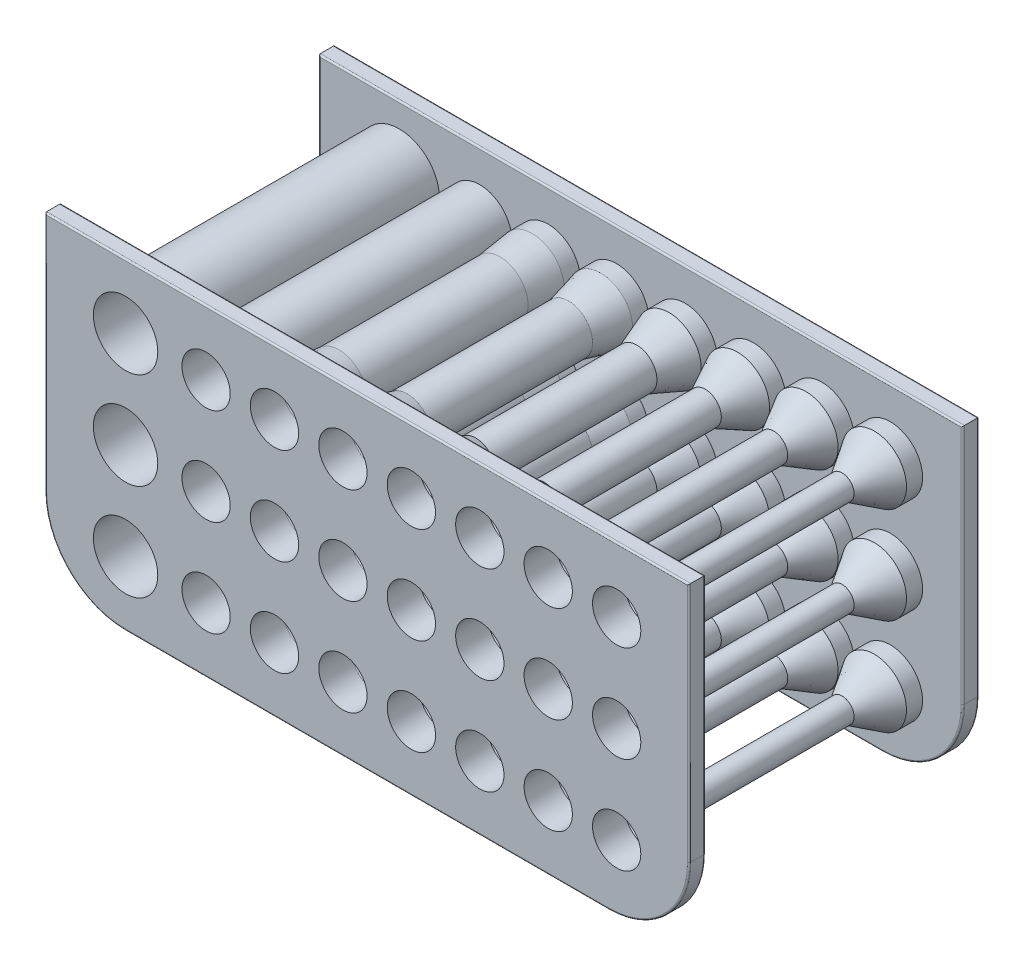
from build123d import *

# Parameters (mm, degrees)
SKIZZE1_R                          = 5
SKIZZE1_R_2                        = 4
EXTRUDE_THIN2_DEPTH                = 18
SKIZZE1_R_3                        = 3
EXTRUDE_THIN2_2_DEPTH              = 18
SKIZZE1_R_4                        = 3.5
SKIZZE1_R_5                        = 2.5
EXTRUDE_THIN2_3_DEPTH              = 18
SKIZZE1_R_6                        = 2
EXTRUDE_THIN2_4_DEPTH              = 18
SKIZZE1_R_7                        = 1.5
EXTRUDE_THIN2_5_DEPTH              = 18
SKIZZE1_R_8                        = 1
EXTRUDE_THIN2_6_DEPTH              = 18
SKIZZE1_R_9                        = 1.75
SKIZZE1_R_10                       = 0.75
EXTRUDE_THIN2_7_DEPTH              = 18
SKIZZE1_R_11                       = 0.5
EXTRUDE_THIN2_8_DEPTH              = 18
SKETCH1_W                          = 80
SKETCH1_H                          = 40
BOSS_EXTRUDE1_DEPTH                = 2
FILLET1_R                          = 10
LPATTERN2_COUNT                    = 2
LPATTERN2_PITCH                    = 34
FILLET1_OF_LPATTERN2_R             = 10
SKIZZE1_3_R                        = 4
SKIZZE1_3_R_2                      = 3
SKIZZE1_3_R_3                      = 2.5
SKIZZE1_3_R_4                      = 2
SKIZZE1_3_R_5                      = 1.5
SKIZZE1_3_R_6                      = 1
SKIZZE1_3_R_7                      = 0.75
SKIZZE1_3_R_8                      = 0.5
CUT_EXTRUDE1_DEPTH                 = 18
SKETCH7_R                          = 4
CUT_EXTRUDE2_DEPTH                 = 8
SKETCH7_3_R                        = 4
SKETCH7_3_R_2                      = 3
EXTRUDE_THIN3_DEPTH                = 4
FILLET3_R                          = 0.2
LINEARES_MUSTER1_COUNT             = 2
LINEARES_MUSTER1_PITCH             = 12
LINEARES_MUSTER1_COUNT_DIR2        = 2
LINEARES_MUSTER1_PITCH_DIR2        = 12
LINEARES_MUSTER1_COPY_1_SKETCH_R   = 4
LINEARES_MUSTER1_COPY_1_DEPTH      = 8
LINEARES_MUSTER1_COPY_2_SKETCH_R   = 4
LINEARES_MUSTER1_COPY_2_DEPTH      = 8
LINEARES_MUSTER1_COPY_3_SKETCH_R   = 4
LINEARES_MUSTER1_COPY_3_DEPTH      = 8
LINEARES_MUSTER1_COPY_4_SKETCH_R   = 4
LINEARES_MUSTER1_COPY_4_SKETCH_R_2 = 3
LINEARES_MUSTER1_COPY_4_DEPTH      = 4
LINEARES_MUSTER1_COPY_5_SKETCH_R   = 4
LINEARES_MUSTER1_COPY_5_SKETCH_R_2 = 3
LINEARES_MUSTER1_COPY_5_DEPTH      = 4
LINEARES_MUSTER1_COPY_6_SKETCH_R   = 4
LINEARES_MUSTER1_COPY_6_SKETCH_R_2 = 3
LINEARES_MUSTER1_COPY_6_DEPTH      = 4


with BuildPart() as part:
    # Skizze1 → Extrude-Thin2 (new, symmetric)
    with BuildSketch(Plane.XY):
        with Locations((-30, 0)):
            Circle(SKIZZE1_R)
        with Locations((-30, 0)):
            Circle(SKIZZE1_R_2, mode=Mode.SUBTRACT)
    extrude_thin2 = extrude(amount=EXTRUDE_THIN2_DEPTH, both=True)



with BuildPart() as body_2:
    # Skizze1 → Extrude-Thin2 2 (new, symmetric)
    with BuildSketch(Plane.XY):
        with Locations((-20, 0)):
            Circle(SKIZZE1_R_2)
        with Locations((-20, 0)):
            Circle(SKIZZE1_R_3, mode=Mode.SUBTRACT)
    extrude_thin2_2 = extrude(amount=EXTRUDE_THIN2_2_DEPTH, both=True)


with BuildPart() as body_3:
    # Skizze1 → Extrude-Thin2 3 (new, symmetric)
    with BuildSketch(Plane.XY):
        with Locations((-11.5, 0)):
            Circle(SKIZZE1_R_4)
        with Locations((-11.5, 0)):
            Circle(SKIZZE1_R_5, mode=Mode.SUBTRACT)
    extrude_thin2_3 = extrude(amount=EXTRUDE_THIN2_3_DEPTH, both=True)


with BuildPart() as body_4:
    # Skizze1 → Extrude-Thin2 4 (new, symmetric)
    with BuildSketch(Plane.XY):
        with Locations((-3, 0)):
            Circle(SKIZZE1_R_3)
        with Locations((-3, 0)):
            Circle(SKIZZE1_R_6, mode=Mode.SUBTRACT)
    extrude_thin2_4 = extrude(amount=EXTRUDE_THIN2_4_DEPTH, both=True)


with BuildPart() as body_5:
    # Skizze1 → Extrude-Thin2 5 (new, symmetric)
    with BuildSketch(Plane.XY):
        with Locations((5.5, 0)):
            Circle(SKIZZE1_R_5)
        with Locations((5.5, 0)):
            Circle(SKIZZE1_R_7, mode=Mode.SUBTRACT)
    extrude_thin2_5 = extrude(amount=EXTRUDE_THIN2_5_DEPTH, both=True)


with BuildPart() as body_6:
    # Skizze1 → Extrude-Thin2 6 (new, symmetric)
    with BuildSketch(Plane.XY):
        with Locations((14, 0)):
            Circle(SKIZZE1_R_6)
        with Locations((14, 0)):
            Circle(SKIZZE1_R_8, mode=Mode.SUBTRACT)
    extrude_thin2_6 = extrude(amount=EXTRUDE_THIN2_6_DEPTH, both=True)


with BuildPart() as body_7:
    # Skizze1 → Extrude-Thin2 7 (new, symmetric)
    with BuildSketch(Plane.XY):
        with Locations((22.5, 0)):
            Circle(SKIZZE1_R_9)
        with Locations((22.5, 0)):
            Circle(SKIZZE1_R_10, mode=Mode.SUBTRACT)
    extrude_thin2_7 = extrude(amount=EXTRUDE_THIN2_7_DEPTH, both=True)


with BuildPart() as body_8:
    # Skizze1 → Extrude-Thin2 8 (new, symmetric)
    with BuildSketch(Plane.XY):
        with Locations((31, 0)):
            Circle(SKIZZE1_R_7)
        with Locations((31, 0)):
            Circle(SKIZZE1_R_11, mode=Mode.SUBTRACT)
    extrude_thin2_8 = extrude(amount=EXTRUDE_THIN2_8_DEPTH, both=True)


with BuildPart() as part_1:
    add(part.part)

    add(body_2.part)  # Boss-Extrude1 merges body 2

    add(body_3.part)  # Boss-Extrude1 merges body 3

    add(body_4.part)  # Boss-Extrude1 merges body 4

    add(body_5.part)  # Boss-Extrude1 merges body 5

    add(body_6.part)  # Boss-Extrude1 merges body 6

    add(body_7.part)  # Boss-Extrude1 merges body 7

    add(body_8.part)  # Boss-Extrude1 merges body 8
    # Sketch1 → Boss-Extrude1 (add)
    with BuildSketch(Plane.XY.offset(18)):
        Rectangle(SKETCH1_W, SKETCH1_H)
    boss_extrude1 = extrude(amount=-BOSS_EXTRUDE1_DEPTH)

    # Fillet1
    fillet1_edges = [part_1.edges().sort_by_distance(p)[0] for p in [
        (40, -20, 17),
        (-40, -20, 17),
    ]]
    fillet(fillet1_edges, radius=FILLET1_R)

    # LPattern2: Boss-Extrude1 ×2
    with Locations(*[(0, 0, -i * LPATTERN2_PITCH) for i in range(1, LPATTERN2_COUNT)]):
        add(boss_extrude1)

    # Fillet1 of LPattern2
    fillet1_of_lpattern2_edges = [part_1.edges().sort_by_distance(p)[0] for p in [
        (40, -20, -17),
        (-40, -20, -17),
    ]]
    fillet(fillet1_of_lpattern2_edges, radius=FILLET1_OF_LPATTERN2_R)

    # Skizze1_3 → Cut-Extrude1 (cut, symmetric)
    with BuildSketch(Plane.XY):
        with Locations((-30, 0)):
            Circle(SKIZZE1_3_R)
        with Locations((-20, 0)):
            Circle(SKIZZE1_3_R_2)
        with Locations((-11.5, 0)):
            Circle(SKIZZE1_3_R_3)
        with Locations((-3, 0)):
            Circle(SKIZZE1_3_R_4)
        with Locations((5.5, 0)):
            Circle(SKIZZE1_3_R_5)
        with Locations((14, 0)):
            Circle(SKIZZE1_3_R_6)
        with Locations((22.5, 0)):
            Circle(SKIZZE1_3_R_7)
        with Locations((31, 0)):
            Circle(SKIZZE1_3_R_8)
    cut_extrude1 = extrude(amount=CUT_EXTRUDE1_DEPTH, both=True, mode=Mode.SUBTRACT)

    # Sketch7 → Cut-Extrude2 (cut)
    with BuildSketch(Plane.XY.offset(18)):
        with Locations((31, 0)):
            Circle(SKETCH7_R)
        with Locations((22.5, 0)):
            Circle(SKETCH7_R)
        with Locations((14, 0)):
            Circle(SKETCH7_R)
        with Locations((5.5, 0)):
            Circle(SKETCH7_R)
        with Locations((-3, 0)):
            Circle(SKETCH7_R)
        with Locations((-11.5, 0)):
            Circle(SKETCH7_R)
    cut_extrude2 = extrude(amount=-CUT_EXTRUDE2_DEPTH, mode=Mode.SUBTRACT)

    # Sketch7_3 → Extrude-Thin3 (add)
    with BuildSketch(Plane.XY.offset(18)):
        with Locations((31, 0)):
            Circle(SKETCH7_3_R)
        with Locations((31, 0)):
            Circle(SKETCH7_3_R_2, mode=Mode.SUBTRACT)
        with Locations((22.5, 0)):
            Circle(SKETCH7_3_R)
        with Locations((22.5, 0)):
            Circle(SKETCH7_3_R_2, mode=Mode.SUBTRACT)
        with Locations((14, 0)):
            Circle(SKETCH7_3_R)
        with Locations((14, 0)):
            Circle(SKETCH7_3_R_2, mode=Mode.SUBTRACT)
        with Locations((5.5, 0)):
            Circle(SKETCH7_3_R)
        with Locations((5.5, 0)):
            Circle(SKETCH7_3_R_2, mode=Mode.SUBTRACT)
        with Locations((-3, 0)):
            Circle(SKETCH7_3_R)
        with Locations((-3, 0)):
            Circle(SKETCH7_3_R_2, mode=Mode.SUBTRACT)
        with Locations((-11.5, 0)):
            Circle(SKETCH7_3_R)
        with Locations((-11.5, 0)):
            Circle(SKETCH7_3_R_2, mode=Mode.SUBTRACT)
    extrude_thin3 = extrude(amount=-EXTRUDE_THIN3_DEPTH)

    # Sketch8 → Revolve2 (revolve)
    with BuildSketch(Plane(origin=(0, 0, 0), x_dir=(1, 0, 0), z_dir=(0, 1, 0))):
        Polygon((8.5, -14), (9.5, -14), (8, -10), (7, -10), align=None)
    revolve2 = revolve(axis=Axis((5.5, 0, 14), (0, 0, 1)))

    # Sketch22 → Revolve3 (revolve)
    with BuildSketch(Plane(origin=(0, 0, 0), x_dir=(1, 0, 0), z_dir=(0, 1, 0))):
        Polygon((16, -10), (18, -14), (17, -14), (15, -10), align=None)
    revolve3 = revolve(axis=Axis((14, 0, 14), (0, 0, 1)))

    # Sketch23 → Revolve4 (revolve)
    with BuildSketch(Plane(origin=(0, 0, 0), x_dir=(1, 0, 0), z_dir=(0, 1, 0))):
        Polygon((24.25, -10), (26.5, -14), (25.5, -14), (23.25, -10), align=None)
    revolve4 = revolve(axis=Axis((22.5, 0, 14), (0, 0, 1)))

    # Sketch24 → Revolve5 (revolve)
    with BuildSketch(Plane(origin=(0, 0, 0), x_dir=(1, 0, 0), z_dir=(0, 1, 0))):
        Polygon((35, -14), (34, -14), (31.5, -10), (32.5, -10), align=None)
    revolve5 = revolve(axis=Axis((31, 0, 14), (0, 0, 1)))

    # Skizze2 → Rotation1 (revolve)
    with BuildSketch(Plane(origin=(0, 0, 0), x_dir=(1, 0, 0), z_dir=(0, 1, 0))):
        Polygon((0, -10), (1, -14), (0, -14), (-1, -10), align=None)
    rotation1 = revolve(axis=Axis((-3, 0, 14), (0, 0, 1)))

    # Skizze3 → Rotation2 (revolve)
    with BuildSketch(Plane(origin=(0, 0, 0), x_dir=(1, 0, 0), z_dir=(0, 1, 0))):
        Polygon((-8, -10), (-7.5, -14), (-8.5, -14), (-9, -10), align=None)
    rotation2 = revolve(axis=Axis((-11.5, 0, 14), (0, 0, 1)))

    # Fillet3
    fillet3_edges = [part_1.edges().sort_by_distance(p)[0] for p in [
        (-35, 0, -16),
        (-24, 0, -16),
        (-15, 0, -16),
        (-6, 0, -16),
        (3, 0, -16),
        (12, 0, -16),
        (20.75, 0, -16),
        (29.5, 0, -16),
        (-40, 5, -18),
        (0, 20, -18),
        (0, 20, -16),
        (-40, 5, -16),
        (-40, 5, 16),
        (0, 20, 16),
        (0, 20, 18),
        (-40, 5, 18),
        (0, -20, -16),
        (0, -20, -18),
        (40, 5, -16),
        (-37.071067812, -17.071067812, -16),
        (37.071067812, -17.071067812, -16),
        (40, 5, -18),
        (-37.071067812, -17.071067812, -18),
        (37.071067812, -17.071067812, -18),
        (-34, 0, -18),
        (-34, 0, 18),
        (-23, 0, -18),
        (-23, 0, 18),
        (-14, 0, -18),
        (-5, 0, -18),
        (4, 0, -18),
        (13, 0, -18),
        (21.75, 0, -18),
        (30.5, 0, -18),
        (-24, 0, 16),
        (27, 0, 16),
        (28, 0, 18),
        (18.5, 0, 16),
        (19.5, 0, 18),
        (10, 0, 16),
        (11, 0, 18),
        (1.5, 0, 16),
        (2.5, 0, 18),
        (-7, 0, 16),
        (-6, 0, 18),
        (-15.5, 0, 16),
        (-14.5, 0, 18),
        (0, -20, 18),
        (0, -20, 16),
        (40, 5, 18),
        (-37.071067812, -17.071067812, 18),
        (37.071067812, -17.071067812, 18),
        (40, 5, 16),
        (-37.071067812, -17.071067812, 16),
        (37.071067812, -17.071067812, 16),
        (-35, 0, 16),
    ]]
    fillet(fillet3_edges, radius=FILLET3_R)

    # Spiegeln1: Cut-Extrude2, Extrude-Thin3, Revolve2, Revolve3, Revolve4, Revolve5, Rotation1, Rotation2 across plane
    add(cut_extrude2.mirror(Plane.XY), mode=Mode.SUBTRACT)
    add(extrude_thin3.mirror(Plane.XY))
    add(revolve2.mirror(Plane.XY))
    add(revolve3.mirror(Plane.XY))
    add(revolve4.mirror(Plane.XY))
    add(revolve5.mirror(Plane.XY))
    add(rotation1.mirror(Plane.XY))
    add(rotation2.mirror(Plane.XY))

    # Lineares Muster1: Extrude-Thin2, Extrude-Thin2 2, Extrude-Thin2 3, Extrude-Thin2 4, Extrude-Thin2 5, Extrude-Thin2 6, Extrude-Thin2 7, Extrude-Thin2 8, Cut-Extrude1, Cut-Extrude2, Extrude-Thin3, Revolve2, Revolve3, Revolve4, Revolve5, Rotation1, Rotation2 2 × 2
    with Locations(*[Vector(0, -1, 0) * (i * LINEARES_MUSTER1_PITCH) + Vector(0, 1, 0) * (j * LINEARES_MUSTER1_PITCH_DIR2) for i in range(LINEARES_MUSTER1_COUNT) for j in range(LINEARES_MUSTER1_COUNT_DIR2) if (i, j) != (0, 0)]):
        add(extrude_thin2)
        add(extrude_thin2_2)
        add(extrude_thin2_3)
        add(extrude_thin2_4)
        add(extrude_thin2_5)
        add(extrude_thin2_6)
        add(extrude_thin2_7)
        add(extrude_thin2_8)
        add(cut_extrude1, mode=Mode.SUBTRACT)
        add(cut_extrude2, mode=Mode.SUBTRACT)
        add(extrude_thin3)
        add(revolve2)
        add(revolve3)
        add(revolve4)
        add(revolve5)
        add(rotation1)
        add(rotation2)

    # Lineares Muster1 copy 1 sketch → Lineares Muster1 copy 1 (cut)
    with BuildSketch(Plane(origin=(0, 12, -18), x_dir=(1, 0, 0), z_dir=(0, 0, -1))):
        with Locations((31, 0)):
            Circle(LINEARES_MUSTER1_COPY_1_SKETCH_R)
        with Locations((22.5, 0)):
            Circle(LINEARES_MUSTER1_COPY_1_SKETCH_R)
        with Locations((14, 0)):
            Circle(LINEARES_MUSTER1_COPY_1_SKETCH_R)
        with Locations((5.5, 0)):
            Circle(LINEARES_MUSTER1_COPY_1_SKETCH_R)
        with Locations((-3, 0)):
            Circle(LINEARES_MUSTER1_COPY_1_SKETCH_R)
        with Locations((-11.5, 0)):
            Circle(LINEARES_MUSTER1_COPY_1_SKETCH_R)
    extrude(amount=-LINEARES_MUSTER1_COPY_1_DEPTH, mode=Mode.SUBTRACT)

    # Lineares Muster1 copy 2 sketch → Lineares Muster1 copy 2 (cut)
    with BuildSketch(Plane(origin=(0, -12, -18), x_dir=(1, 0, 0), z_dir=(0, 0, -1))):
        with Locations((31, 0)):
            Circle(LINEARES_MUSTER1_COPY_2_SKETCH_R)
        with Locations((22.5, 0)):
            Circle(LINEARES_MUSTER1_COPY_2_SKETCH_R)
        with Locations((14, 0)):
            Circle(LINEARES_MUSTER1_COPY_2_SKETCH_R)
        with Locations((5.5, 0)):
            Circle(LINEARES_MUSTER1_COPY_2_SKETCH_R)
        with Locations((-3, 0)):
            Circle(LINEARES_MUSTER1_COPY_2_SKETCH_R)
        with Locations((-11.5, 0)):
            Circle(LINEARES_MUSTER1_COPY_2_SKETCH_R)
    extrude(amount=-LINEARES_MUSTER1_COPY_2_DEPTH, mode=Mode.SUBTRACT)

    # Lineares Muster1 copy 3 sketch → Lineares Muster1 copy 3 (cut)
    with BuildSketch(Plane(origin=(0, 0, -18), x_dir=(1, 0, 0), z_dir=(0, 0, -1))):
        with Locations((31, 0)):
            Circle(LINEARES_MUSTER1_COPY_3_SKETCH_R)
        with Locations((22.5, 0)):
            Circle(LINEARES_MUSTER1_COPY_3_SKETCH_R)
        with Locations((14, 0)):
            Circle(LINEARES_MUSTER1_COPY_3_SKETCH_R)
        with Locations((5.5, 0)):
            Circle(LINEARES_MUSTER1_COPY_3_SKETCH_R)
        with Locations((-3, 0)):
            Circle(LINEARES_MUSTER1_COPY_3_SKETCH_R)
        with Locations((-11.5, 0)):
            Circle(LINEARES_MUSTER1_COPY_3_SKETCH_R)
    extrude(amount=-LINEARES_MUSTER1_COPY_3_DEPTH, mode=Mode.SUBTRACT)

    # Lineares Muster1 copy 4 sketch → Lineares Muster1 copy 4 (add)
    with BuildSketch(Plane(origin=(0, 12, -18), x_dir=(1, 0, 0), z_dir=(0, 0, -1))):
        with Locations((31, 0)):
            Circle(LINEARES_MUSTER1_COPY_4_SKETCH_R)
        with Locations((31, 0)):
            Circle(LINEARES_MUSTER1_COPY_4_SKETCH_R_2, mode=Mode.SUBTRACT)
        with Locations((22.5, 0)):
            Circle(LINEARES_MUSTER1_COPY_4_SKETCH_R)
        with Locations((22.5, 0)):
            Circle(LINEARES_MUSTER1_COPY_4_SKETCH_R_2, mode=Mode.SUBTRACT)
        with Locations((14, 0)):
            Circle(LINEARES_MUSTER1_COPY_4_SKETCH_R)
        with Locations((14, 0)):
            Circle(LINEARES_MUSTER1_COPY_4_SKETCH_R_2, mode=Mode.SUBTRACT)
        with Locations((5.5, 0)):
            Circle(LINEARES_MUSTER1_COPY_4_SKETCH_R)
        with Locations((5.5, 0)):
            Circle(LINEARES_MUSTER1_COPY_4_SKETCH_R_2, mode=Mode.SUBTRACT)
        with Locations((-3, 0)):
            Circle(LINEARES_MUSTER1_COPY_4_SKETCH_R)
        with Locations((-3, 0)):
            Circle(LINEARES_MUSTER1_COPY_4_SKETCH_R_2, mode=Mode.SUBTRACT)
        with Locations((-11.5, 0)):
            Circle(LINEARES_MUSTER1_COPY_4_SKETCH_R)
        with Locations((-11.5, 0)):
            Circle(LINEARES_MUSTER1_COPY_4_SKETCH_R_2, mode=Mode.SUBTRACT)
    extrude(amount=-LINEARES_MUSTER1_COPY_4_DEPTH)

    # Lineares Muster1 copy 5 sketch → Lineares Muster1 copy 5 (add)
    with BuildSketch(Plane(origin=(0, -12, -18), x_dir=(1, 0, 0), z_dir=(0, 0, -1))):
        with Locations((31, 0)):
            Circle(LINEARES_MUSTER1_COPY_5_SKETCH_R)
        with Locations((31, 0)):
            Circle(LINEARES_MUSTER1_COPY_5_SKETCH_R_2, mode=Mode.SUBTRACT)
        with Locations((22.5, 0)):
            Circle(LINEARES_MUSTER1_COPY_5_SKETCH_R)
        with Locations((22.5, 0)):
            Circle(LINEARES_MUSTER1_COPY_5_SKETCH_R_2, mode=Mode.SUBTRACT)
        with Locations((14, 0)):
            Circle(LINEARES_MUSTER1_COPY_5_SKETCH_R)
        with Locations((14, 0)):
            Circle(LINEARES_MUSTER1_COPY_5_SKETCH_R_2, mode=Mode.SUBTRACT)
        with Locations((5.5, 0)):
            Circle(LINEARES_MUSTER1_COPY_5_SKETCH_R)
        with Locations((5.5, 0)):
            Circle(LINEARES_MUSTER1_COPY_5_SKETCH_R_2, mode=Mode.SUBTRACT)
        with Locations((-3, 0)):
            Circle(LINEARES_MUSTER1_COPY_5_SKETCH_R)
        with Locations((-3, 0)):
            Circle(LINEARES_MUSTER1_COPY_5_SKETCH_R_2, mode=Mode.SUBTRACT)
        with Locations((-11.5, 0)):
            Circle(LINEARES_MUSTER1_COPY_5_SKETCH_R)
        with Locations((-11.5, 0)):
            Circle(LINEARES_MUSTER1_COPY_5_SKETCH_R_2, mode=Mode.SUBTRACT)
    extrude(amount=-LINEARES_MUSTER1_COPY_5_DEPTH)

    # Lineares Muster1 copy 6 sketch → Lineares Muster1 copy 6 (add)
    with BuildSketch(Plane(origin=(0, 0, -18), x_dir=(1, 0, 0), z_dir=(0, 0, -1))):
        with Locations((31, 0)):
            Circle(LINEARES_MUSTER1_COPY_6_SKETCH_R)
        with Locations((31, 0)):
            Circle(LINEARES_MUSTER1_COPY_6_SKETCH_R_2, mode=Mode.SUBTRACT)
        with Locations((22.5, 0)):
            Circle(LINEARES_MUSTER1_COPY_6_SKETCH_R)
        with Locations((22.5, 0)):
            Circle(LINEARES_MUSTER1_COPY_6_SKETCH_R_2, mode=Mode.SUBTRACT)
        with Locations((14, 0)):
            Circle(LINEARES_MUSTER1_COPY_6_SKETCH_R)
        with Locations((14, 0)):
            Circle(LINEARES_MUSTER1_COPY_6_SKETCH_R_2, mode=Mode.SUBTRACT)
        with Locations((5.5, 0)):
            Circle(LINEARES_MUSTER1_COPY_6_SKETCH_R)
        with Locations((5.5, 0)):
            Circle(LINEARES_MUSTER1_COPY_6_SKETCH_R_2, mode=Mode.SUBTRACT)
        with Locations((-3, 0)):
            Circle(LINEARES_MUSTER1_COPY_6_SKETCH_R)
        with Locations((-3, 0)):
            Circle(LINEARES_MUSTER1_COPY_6_SKETCH_R_2, mode=Mode.SUBTRACT)
        with Locations((-11.5, 0)):
            Circle(LINEARES_MUSTER1_COPY_6_SKETCH_R)
        with Locations((-11.5, 0)):
            Circle(LINEARES_MUSTER1_COPY_6_SKETCH_R_2, mode=Mode.SUBTRACT)
    extrude(amount=-LINEARES_MUSTER1_COPY_6_DEPTH)

    # Lineares Muster1 copy 7 sketch → Lineares Muster1 copy 7 (revolve)
    with BuildSketch(Plane(origin=(0, 12, 0), x_dir=(1, 0, 0), z_dir=(0, 1, 0))):
        Polygon((8.5, 14), (9.5, 14), (8, 10), (7, 10), align=None)
    revolve(axis=Axis((5.5, 12, -14), (0, 0, 1)))

    # Lineares Muster1 copy 8 sketch → Lineares Muster1 copy 8 (revolve)
    with BuildSketch(Plane(origin=(0, -12, 0), x_dir=(1, 0, 0), z_dir=(0, 1, 0))):
        Polygon((8.5, 14), (9.5, 14), (8, 10), (7, 10), align=None)
    revolve(axis=Axis((5.5, -12, -14), (0, 0, 1)))

    # Lineares Muster1 copy 9 sketch → Lineares Muster1 copy 9 (revolve)
    with BuildSketch(Plane(origin=(0, 0, 0), x_dir=(1, 0, 0), z_dir=(0, 1, 0))):
        Polygon((8.5, 14), (9.5, 14), (8, 10), (7, 10), align=None)
    revolve(axis=Axis((5.5, 0, -14), (0, 0, 1)))

    # Lineares Muster1 copy 10 sketch → Lineares Muster1 copy 10 (revolve)
    with BuildSketch(Plane(origin=(0, 12, 0), x_dir=(1, 0, 0), z_dir=(0, 1, 0))):
        Polygon((16, 10), (18, 14), (17, 14), (15, 10), align=None)
    revolve(axis=Axis((14, 12, -14), (0, 0, 1)))

    # Lineares Muster1 copy 11 sketch → Lineares Muster1 copy 11 (revolve)
    with BuildSketch(Plane(origin=(0, -12, 0), x_dir=(1, 0, 0), z_dir=(0, 1, 0))):
        Polygon((16, 10), (18, 14), (17, 14), (15, 10), align=None)
    revolve(axis=Axis((14, -12, -14), (0, 0, 1)))

    # Lineares Muster1 copy 12 sketch → Lineares Muster1 copy 12 (revolve)
    with BuildSketch(Plane(origin=(0, 0, 0), x_dir=(1, 0, 0), z_dir=(0, 1, 0))):
        Polygon((16, 10), (18, 14), (17, 14), (15, 10), align=None)
    revolve(axis=Axis((14, 0, -14), (0, 0, 1)))

    # Lineares Muster1 copy 13 sketch → Lineares Muster1 copy 13 (revolve)
    with BuildSketch(Plane(origin=(0, 12, 0), x_dir=(1, 0, 0), z_dir=(0, 1, 0))):
        Polygon((24.25, 10), (26.5, 14), (25.5, 14), (23.25, 10), align=None)
    revolve(axis=Axis((22.5, 12, -14), (0, 0, 1)))

    # Lineares Muster1 copy 14 sketch → Lineares Muster1 copy 14 (revolve)
    with BuildSketch(Plane(origin=(0, -12, 0), x_dir=(1, 0, 0), z_dir=(0, 1, 0))):
        Polygon((24.25, 10), (26.5, 14), (25.5, 14), (23.25, 10), align=None)
    revolve(axis=Axis((22.5, -12, -14), (0, 0, 1)))

    # Lineares Muster1 copy 15 sketch → Lineares Muster1 copy 15 (revolve)
    with BuildSketch(Plane(origin=(0, 0, 0), x_dir=(1, 0, 0), z_dir=(0, 1, 0))):
        Polygon((24.25, 10), (26.5, 14), (25.5, 14), (23.25, 10), align=None)
    revolve(axis=Axis((22.5, 0, -14), (0, 0, 1)))

    # Lineares Muster1 copy 16 sketch → Lineares Muster1 copy 16 (revolve)
    with BuildSketch(Plane(origin=(0, 12, 0), x_dir=(1, 0, 0), z_dir=(0, 1, 0))):
        Polygon((35, 14), (34, 14), (31.5, 10), (32.5, 10), align=None)
    revolve(axis=Axis((31, 12, -14), (0, 0, 1)))

    # Lineares Muster1 copy 17 sketch → Lineares Muster1 copy 17 (revolve)
    with BuildSketch(Plane(origin=(0, -12, 0), x_dir=(1, 0, 0), z_dir=(0, 1, 0))):
        Polygon((35, 14), (34, 14), (31.5, 10), (32.5, 10), align=None)
    revolve(axis=Axis((31, -12, -14), (0, 0, 1)))

    # Lineares Muster1 copy 18 sketch → Lineares Muster1 copy 18 (revolve)
    with BuildSketch(Plane(origin=(0, 0, 0), x_dir=(1, 0, 0), z_dir=(0, 1, 0))):
        Polygon((35, 14), (34, 14), (31.5, 10), (32.5, 10), align=None)
    revolve(axis=Axis((31, 0, -14), (0, 0, 1)))

    # Lineares Muster1 copy 19 sketch → Lineares Muster1 copy 19 (revolve)
    with BuildSketch(Plane(origin=(0, 12, 0), x_dir=(1, 0, 0), z_dir=(0, 1, 0))):
        Polygon((0, 10), (1, 14), (0, 14), (-1, 10), align=None)
    revolve(axis=Axis((-3, 12, -14), (0, 0, 1)))

    # Lineares Muster1 copy 20 sketch → Lineares Muster1 copy 20 (revolve)
    with BuildSketch(Plane(origin=(0, -12, 0), x_dir=(1, 0, 0), z_dir=(0, 1, 0))):
        Polygon((0, 10), (1, 14), (0, 14), (-1, 10), align=None)
    revolve(axis=Axis((-3, -12, -14), (0, 0, 1)))

    # Lineares Muster1 copy 21 sketch → Lineares Muster1 copy 21 (revolve)
    with BuildSketch(Plane(origin=(0, 0, 0), x_dir=(1, 0, 0), z_dir=(0, 1, 0))):
        Polygon((0, 10), (1, 14), (0, 14), (-1, 10), align=None)
    revolve(axis=Axis((-3, 0, -14), (0, 0, 1)))

    # Lineares Muster1 copy 22 sketch → Lineares Muster1 copy 22 (revolve)
    with BuildSketch(Plane(origin=(0, 12, 0), x_dir=(1, 0, 0), z_dir=(0, 1, 0))):
        Polygon((-8, 10), (-7.5, 14), (-8.5, 14), (-9, 10), align=None)
    revolve(axis=Axis((-11.5, 12, -14), (0, 0, 1)))

    # Lineares Muster1 copy 23 sketch → Lineares Muster1 copy 23 (revolve)
    with BuildSketch(Plane(origin=(0, -12, 0), x_dir=(1, 0, 0), z_dir=(0, 1, 0))):
        Polygon((-8, 10), (-7.5, 14), (-8.5, 14), (-9, 10), align=None)
    revolve(axis=Axis((-11.5, -12, -14), (0, 0, 1)))

    # Lineares Muster1 copy 24 sketch → Lineares Muster1 copy 24 (revolve)
    with BuildSketch(Plane(origin=(0, 0, 0), x_dir=(1, 0, 0), z_dir=(0, 1, 0))):
        Polygon((-8, 10), (-7.5, 14), (-8.5, 14), (-9, 10), align=None)
    revolve(axis=Axis((-11.5, 0, -14), (0, 0, 1)))


solid = part_1.part
